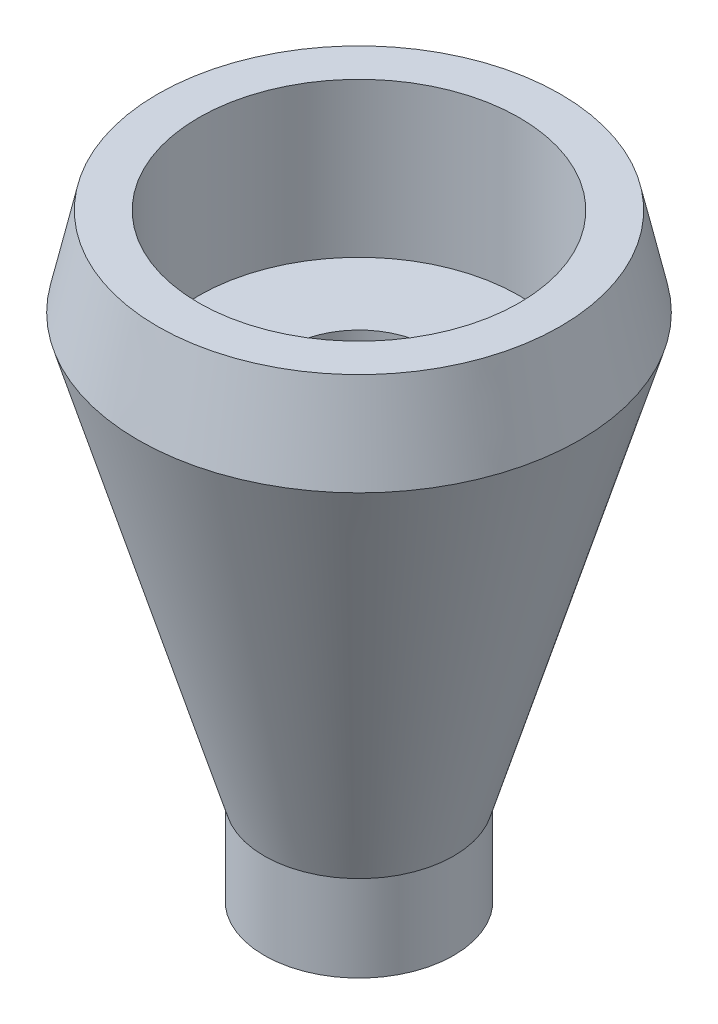
from build123d import *


with BuildPart() as part:
    # Sketch1 → Revolve1 (revolve)
    with BuildSketch(Plane.XY):
        Polygon((0, 0), (0, 6.462135789), (9.462413119, 38.218917378), (7.996532166, 44.865685618), (4.926019535, 44.865685618), (4.926019535, 33.299277886), (-1.754008285, 33.299277886), (-1.754008285, 6.462135789), (-7.108349367, 6.462135789), (-7.108349367, 0), align=None)
    revolve(axis=Axis((-7.108349367, 6.462135789, 0), (0, -1, 0)))


solid = part.part
